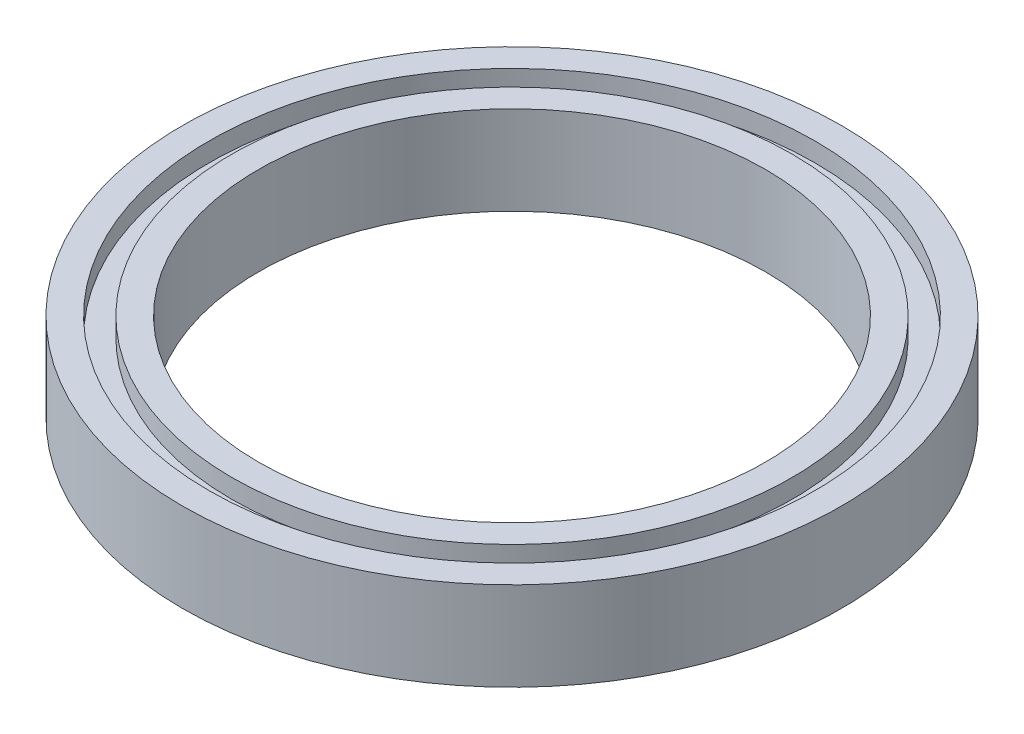
from build123d import *

# Parameters (mm, degrees)
SKETCH_1_R          = 26
SKETCH_1_R_2        = 20
EXTRUDE_1_DEPTH     = 7
SKETCH_2_R          = 23.9
SKETCH_2_R_2        = 22.1
CUT_EXTRUDE_1_DEPTH = 1.5


with BuildPart() as part:
    # 草图1 → 凸台-拉伸1 (new body)
    with BuildSketch(Plane(origin=(0, 0, 0), x_dir=(1, 0, 0), z_dir=(0, 1, 0))):
        Circle(SKETCH_1_R)
        Circle(SKETCH_1_R_2, mode=Mode.SUBTRACT)
    extrude(amount=EXTRUDE_1_DEPTH)

    # 草图2 → 切除-拉伸1 (cut)
    with BuildSketch(Plane(origin=(0, 7, 0), x_dir=(1, 0, 0), z_dir=(0, 1, 0))):
        Circle(SKETCH_2_R)
        Circle(SKETCH_2_R_2, mode=Mode.SUBTRACT)
    cut_extrude_1 = extrude(amount=-CUT_EXTRUDE_1_DEPTH, mode=Mode.SUBTRACT)

    # 镜向1: 切除-拉伸1 across plane
    add(cut_extrude_1.mirror(Plane.ZX.offset(3.5)), mode=Mode.SUBTRACT)


solid = part.part
